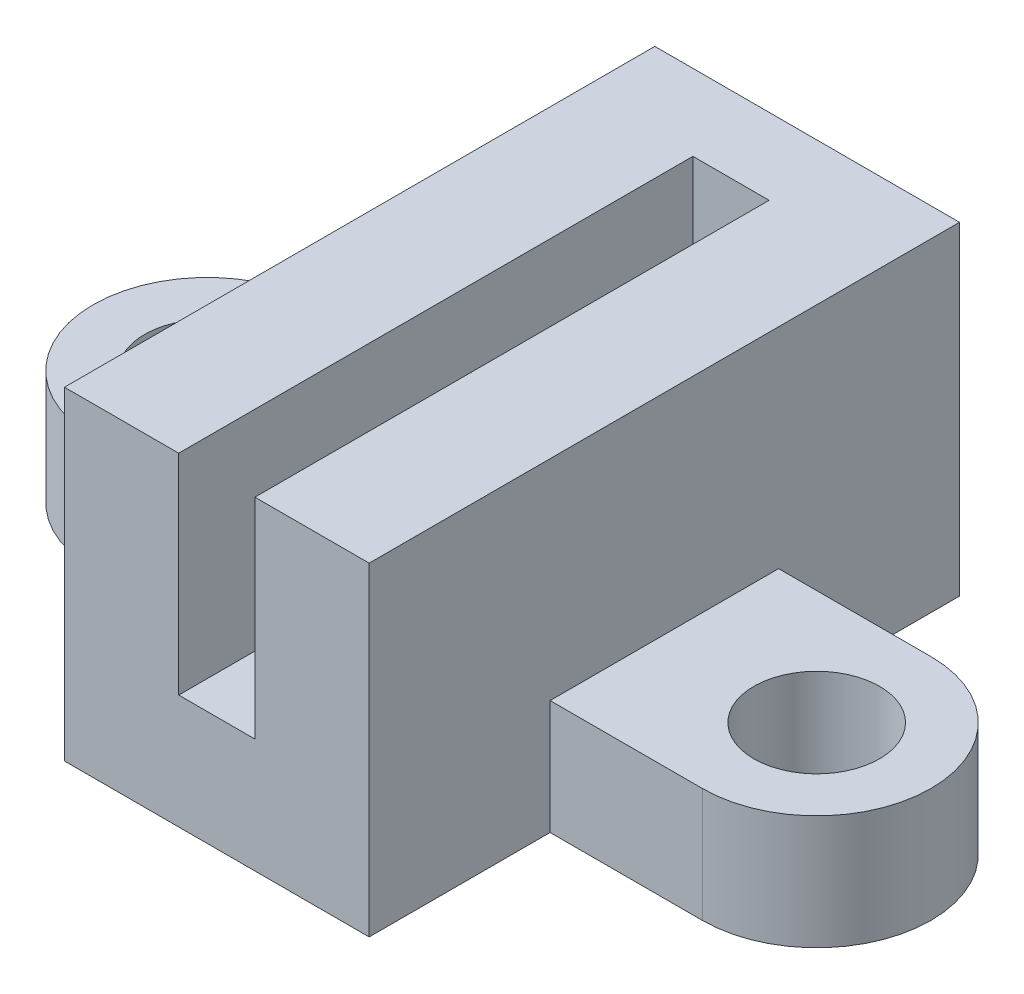
from build123d import *

# Parameters (mm, degrees)
BOSS_EXTRUDE1_DEPTH = 13.5
SKETCH2_W           = 8
SKETCH2_H           = 8.5
BOSS_EXTRUDE2_DEPTH = 2
SKETCH3_R           = 1.65
BOSS_EXTRUDE3_DEPTH = 3


with BuildPart() as part:
    # Sketch1 → Boss-Extrude1 (new body)
    with BuildSketch(Plane.XY):
        Polygon((0, 0), (0, 8.5), (3, 8.5), (3, 3), (5, 3), (5, 8.5), (8, 8.5), (8, 0), align=None)
    extrude(amount=BOSS_EXTRUDE1_DEPTH)

    # Sketch2 → Boss-Extrude2 (add)
    with BuildSketch(Plane(origin=(0, 0, 0), x_dir=(-1, 0, 0), z_dir=(0, 0, -1))):
        with Locations((-4, 4.25)):
            Rectangle(SKETCH2_W, SKETCH2_H)
    extrude(amount=BOSS_EXTRUDE2_DEPTH)

    # Sketch3 → Boss-Extrude3 (add)
    with BuildSketch(Plane(origin=(0, 0, 0), x_dir=(1, 0, 0), z_dir=(0, 1, 0))):
        with BuildLine():
            Line((0, -2.75), (-4, -2.75))
            ThreePointArc((-4, -2.75), (-7, -5.75), (-4, -8.75))
            Line((-4, -8.75), (0, -8.75))
            Line((0, -8.75), (0, -2.75))
        make_face()
        with Locations((-4, -5.75)):
            Circle(SKETCH3_R, mode=Mode.SUBTRACT)
        with BuildLine():
            Line((8, -2.75), (12, -2.75))
            ThreePointArc((12, -2.75), (15, -5.75), (12, -8.75))
            Line((12, -8.75), (8, -8.75))
            Line((8, -8.75), (8, -2.75))
        make_face()
        with Locations((12, -5.75)):
            Circle(SKETCH3_R, mode=Mode.SUBTRACT)
    extrude(amount=BOSS_EXTRUDE3_DEPTH)


solid = part.part
